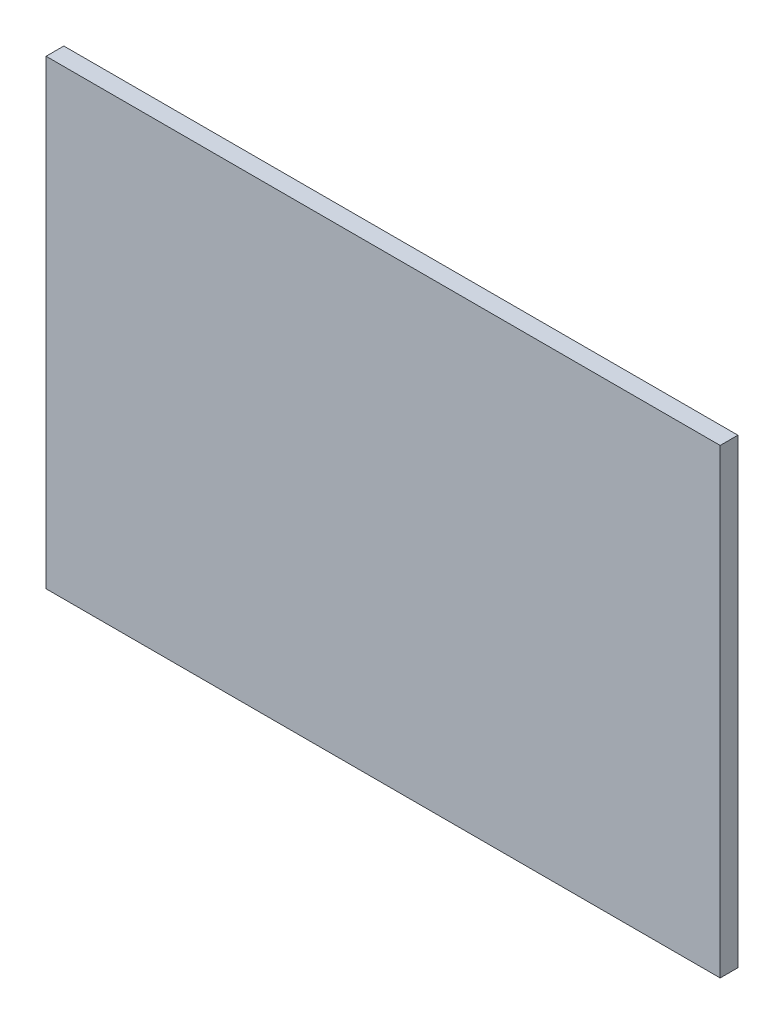
from build123d import *

# Parameters (mm, degrees)
SKETCH1_W           = 38
SKETCH1_H           = 26
BOSS_EXTRUDE1_DEPTH = 1


with BuildPart() as part:
    # Sketch1 → Boss-Extrude1 (new body)
    with BuildSketch(Plane.XY):
        with Locations((19, 13)):
            Rectangle(SKETCH1_W, SKETCH1_H)
    extrude(amount=BOSS_EXTRUDE1_DEPTH)


solid = part.part
